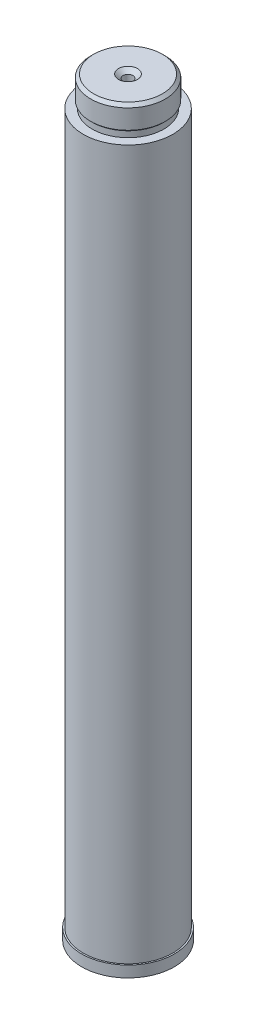
from build123d import *

# Parameters (mm, degrees)
SKETCH1_R                                           = 39.37
BOSS_EXTRUDE1_DEPTH                                 = 9.525
SKETCH2_R                                           = 38.1
BOSS_EXTRUDE2_DEPTH                                 = 603.25
SHELL1_T                                            = -2.54
CSK_FOR_5_16_FLAT_HEAD_MACHINE_SCREW_10_D           = 8.4328
CSK_FOR_5_16_FLAT_HEAD_MACHINE_SCREW_10_DEPTH       = 12.7
CSK_FOR_5_16_FLAT_HEAD_MACHINE_SCREW_10_CSINK_D     = 16.129
CSK_FOR_5_16_FLAT_HEAD_MACHINE_SCREW_10_CSINK_ANGLE = 100
CSK_FOR_5_16_FLAT_HEAD_MACHINE_SCREW_10_TIP         = 2.533468714


with BuildPart() as part:
    # Sketch1 → Boss-Extrude1 (new body)
    with BuildSketch(Plane(origin=(0, 0, 0), x_dir=(1, 0, 0), z_dir=(0, 1, 0))):
        with Locations(Location((0, 0, 0), (0, 0, 90))):
            Circle(SKETCH1_R)
    extrude(amount=BOSS_EXTRUDE1_DEPTH)

    # Sketch2 → Boss-Extrude2 (add)
    with BuildSketch(Plane(origin=(0, 9.525, 0), x_dir=(1, 0, 0), z_dir=(0, 1, 0))):
        with Locations(Location((0, 0, 0), (0, 0, 270))):
            Circle(SKETCH2_R)
    extrude(amount=BOSS_EXTRUDE2_DEPTH)

    # Shell1
    shell1_openings = [part.faces().sort_by_distance(p)[0] for p in [
        (0, 0, 0),
    ]]
    offset(amount=SHELL1_T, openings=shell1_openings, kind=Kind.INTERSECTION)

    # Sketch4 → Revolve1 (revolve)
    with BuildSketch(Plane.XY, mode=Mode.PRIVATE) as revolve1_sk:
        Polygon((0, 612.775), (30.48, 612.775), (30.48, 617.855), (31.75, 619.125), (31.75, 635.635), (29.21, 638.175), (0, 638.175), align=None)
    revolve(revolve1_sk.sketch.rotate(Axis((0, 0, 0), (0, 1, 0)), 90), axis=Axis((0, 0, 0), (0, 1, 0)))

    # CSK for 5/16 Flat Head Machine Screw (100)1
    with Locations(Plane(origin=(0, 638.175, 0), x_dir=(1, 0, 0), z_dir=(0, 1, 0))):
        with Locations((0, 0)):
            CounterSinkHole(CSK_FOR_5_16_FLAT_HEAD_MACHINE_SCREW_10_D / 2, CSK_FOR_5_16_FLAT_HEAD_MACHINE_SCREW_10_CSINK_D / 2, depth=CSK_FOR_5_16_FLAT_HEAD_MACHINE_SCREW_10_DEPTH, counter_sink_angle=CSK_FOR_5_16_FLAT_HEAD_MACHINE_SCREW_10_CSINK_ANGLE)
            with Locations((0, 0, -(CSK_FOR_5_16_FLAT_HEAD_MACHINE_SCREW_10_DEPTH + CSK_FOR_5_16_FLAT_HEAD_MACHINE_SCREW_10_TIP / 2))):  # 118° drill point
                Cone(0, CSK_FOR_5_16_FLAT_HEAD_MACHINE_SCREW_10_D / 2, CSK_FOR_5_16_FLAT_HEAD_MACHINE_SCREW_10_TIP, mode=Mode.SUBTRACT)


solid = part.part
